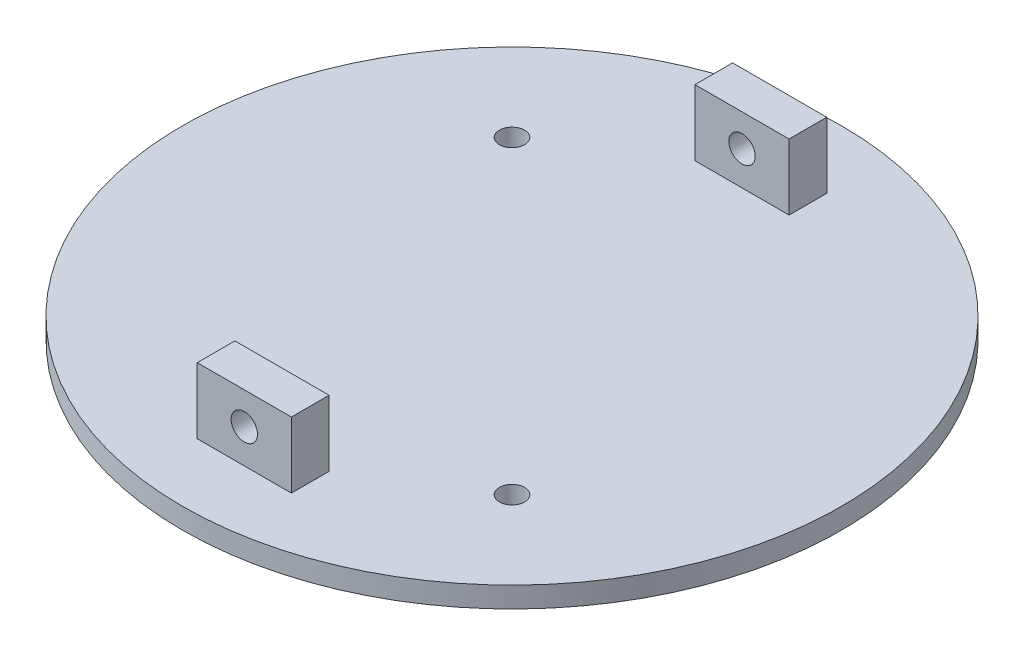
from build123d import *

# Parameters (mm, degrees)
SKETCH1_R           = 44.45
SKETCH1_R_2         = 1.7
BOSS_EXTRUDE1_DEPTH = 2.794
SKETCH3_W           = 12.7
SKETCH3_H           = 5.08
BOSS_EXTRUDE2_DEPTH = 8.89
SKETCH4_R           = 1.778
CUT_EXTRUDE1_DEPTH  = 13.208
CIRPATTERN1_COUNT   = 2


with BuildPart() as part:
    # Sketch1 → Boss-Extrude1 (new body)
    with BuildSketch(Plane(origin=(0, 0, 0), x_dir=(1, 0, 0), z_dir=(0, 1, 0))):
        with Locations(Location((44.45, 44.45, 0), (0, 0, 270))):
            Circle(SKETCH1_R)
        with Locations(Location((65.31404504, 23.58595496, 0), (0, 0, 270))):
            Circle(SKETCH1_R_2, mode=Mode.SUBTRACT)
        with Locations(Location((23.58595496, 65.31404504, 0), (0, 0, 270))):
            Circle(SKETCH1_R_2, mode=Mode.SUBTRACT)
    extrude(amount=BOSS_EXTRUDE1_DEPTH)

    # Sketch3 → Boss-Extrude2 (add)
    with BuildSketch(Plane(origin=(0, 2.794, 0), x_dir=(1, 0, 0), z_dir=(0, 1, 0))):
        with Locations((44.99404504, 77.47)):
            Rectangle(SKETCH3_W, SKETCH3_H)
        with Locations((43.90595496, 11.43)):
            Rectangle(SKETCH3_W, SKETCH3_H)
    extrude(amount=BOSS_EXTRUDE2_DEPTH)

    # Sketch4 → Cut-Extrude1 (cut)
    with BuildSketch(Plane.XY.offset(-8.89)):
        with Locations((43.90595496, 7.366)):
            Circle(SKETCH4_R)
    cut_extrude1 = extrude(amount=-CUT_EXTRUDE1_DEPTH, mode=Mode.SUBTRACT)

    # CirPattern1: Cut-Extrude1 ×2 about axis
    cirpattern1_axis = Axis((44.45, 2.794, -44.45), (0, 1, 0))
    for i in range(1, CIRPATTERN1_COUNT):
        add(cut_extrude1.rotate(cirpattern1_axis, i * 360 / CIRPATTERN1_COUNT), mode=Mode.SUBTRACT)


solid = part.part
